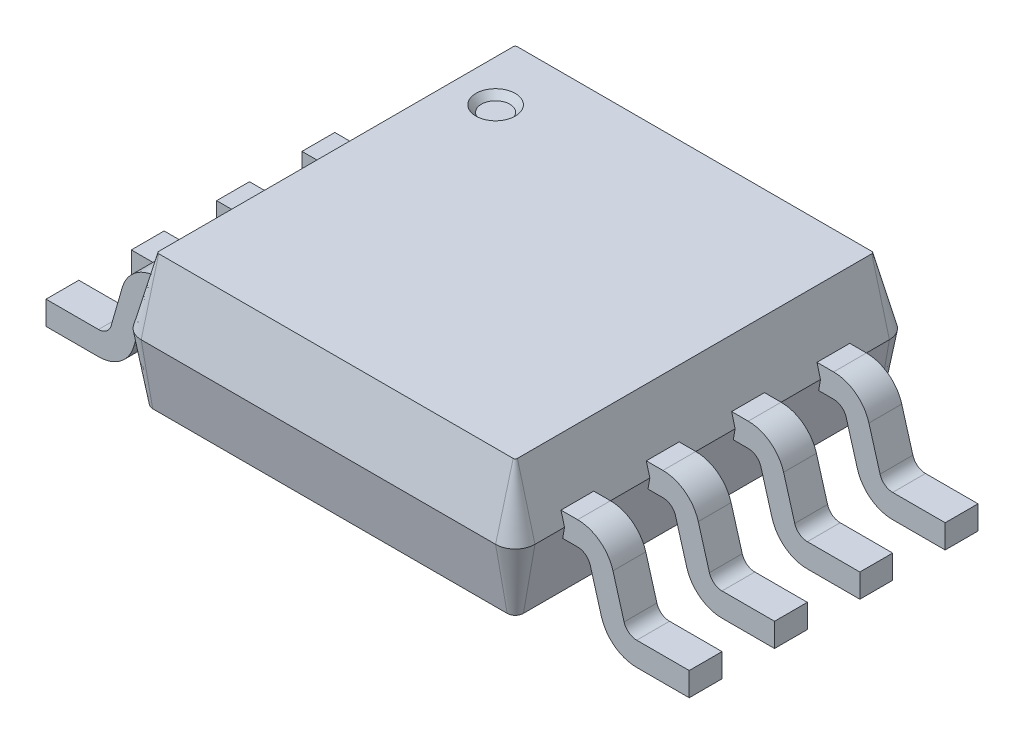
from build123d import *

# Parameters (mm, degrees)
EXTRUDE1_START           = 0.65
EXTRUDE1_DEPTH           = 0.5
EXTRUDE1_TAPER           = 15
EXTRUDE1_OTHER_WAY_DEPTH = 0.5
EXTRUDE1_OTHER_WAY_TAPER = 10
ICE1_START               = 1
ICE1_DEPTH               = 0.125
LPATTERN1_COUNT          = 4
LPATTERN1_PITCH          = 0.65
SKETCH2_R                = 0.15
ICE2_DEPTH               = 0.05
ICE2_TAPER               = 40


with BuildPart() as part:
    # Sketch1 → Extrude1 (new body)
    with BuildSketch(Plane(origin=(0, 0, 0), x_dir=(1, 0, 0), z_dir=(0, 1, 0)).offset(EXTRUDE1_START)):
        with BuildLine():
            ThreePointArc((-1.35, 1.5), (-1.456066017, 1.456066017), (-1.5, 1.35))
            Line((-1.5, 1.35), (-1.5, -1.35))
            ThreePointArc((-1.5, -1.35), (-1.456066017, -1.456066017), (-1.35, -1.5))
            Line((-1.35, -1.5), (1.35, -1.5))
            ThreePointArc((1.35, -1.5), (1.456066017, -1.456066017), (1.5, -1.35))
            Line((1.5, -1.35), (1.5, 1.35))
            ThreePointArc((1.5, 1.35), (1.456066017, 1.456066017), (1.35, 1.5))
            Line((1.35, 1.5), (-1.35, 1.5))
        make_face()
    extrude(amount=EXTRUDE1_DEPTH, taper=EXTRUDE1_TAPER)

    # Sketch1 → Extrude1 other way (add)
    with BuildSketch(Plane(origin=(0, 0, 0), x_dir=(1, 0, 0), z_dir=(0, 1, 0)).offset(EXTRUDE1_START)):
        with BuildLine():
            ThreePointArc((-1.35, 1.5), (-1.456066017, 1.456066017), (-1.5, 1.35))
            Line((-1.5, 1.35), (-1.5, -1.35))
            ThreePointArc((-1.5, -1.35), (-1.456066017, -1.456066017), (-1.35, -1.5))
            Line((-1.35, -1.5), (1.35, -1.5))
            ThreePointArc((1.35, -1.5), (1.456066017, -1.456066017), (1.5, -1.35))
            Line((1.5, -1.35), (1.5, 1.35))
            ThreePointArc((1.5, 1.35), (1.456066017, 1.456066017), (1.35, 1.5))
            Line((1.35, 1.5), (-1.35, 1.5))
        make_face()
    extrude(amount=-EXTRUDE1_OTHER_WAY_DEPTH, taper=EXTRUDE1_OTHER_WAY_TAPER)

    # Sketch3 → ICE1 (add, symmetric)
    with BuildSketch(Plane.XY.offset(ICE1_START)):
        with BuildLine():
            Line((-2.45, 0), (-2.05, 0))
            ThreePointArc((-2.05, 0), (-1.881563475, 0.05632806), (-1.780896254, 0.202649022))
            Line((-1.780896254, 0.202649022), (-1.696108481, 0.497625349))
            ThreePointArc((-1.696108481, 0.497625349), (-1.660155902, 0.549882836), (-1.6, 0.57))
            Line((-1.6, 0.57), (-1.45, 0.57))
            Line((-1.45, 0.57), (-1.45, 0.75))
            Line((-1.45, 0.75), (-1.6, 0.75))
            ThreePointArc((-1.6, 0.75), (-1.768436525, 0.69367194), (-1.869103746, 0.547350978))
            Line((-1.869103746, 0.547350978), (-1.953891519, 0.252374651))
            ThreePointArc((-1.953891519, 0.252374651), (-1.989844098, 0.200117164), (-2.05, 0.18))
            Line((-2.05, 0.18), (-2.45, 0.18))
            Line((-2.45, 0.18), (-2.45, 0))
        make_face()
        with BuildLine():
            Line((1.45, 0.75), (1.6, 0.75))
            ThreePointArc((1.6, 0.75), (1.768436525, 0.69367194), (1.869103746, 0.547350978))
            Line((1.869103746, 0.547350978), (1.953891519, 0.252374651))
            ThreePointArc((1.953891519, 0.252374651), (1.989844098, 0.200117164), (2.05, 0.18))
            Line((2.05, 0.18), (2.45, 0.18))
            Line((2.45, 0.18), (2.45, 0))
            Line((2.45, 0), (2.05, 0))
            ThreePointArc((2.05, 0), (1.881563475, 0.05632806), (1.780896254, 0.202649022))
            Line((1.780896254, 0.202649022), (1.696108481, 0.497625349))
            ThreePointArc((1.696108481, 0.497625349), (1.660155902, 0.549882836), (1.6, 0.57))
            Line((1.6, 0.57), (1.45, 0.57))
            Line((1.45, 0.57), (1.45, 0.75))
        make_face()
    ice1 = extrude(amount=ICE1_DEPTH, both=True)

    # LPattern1: ICE1 ×4
    with Locations(*[(0, 0, -i * LPATTERN1_PITCH) for i in range(1, LPATTERN1_COUNT)]):
        add(ice1)

    # Sketch2 → ICE2 (cut)
    with BuildSketch(Plane(origin=(0, 1.15, 0), x_dir=(1, 0, 0), z_dir=(0, 1, 0))):
        with Locations((-1.05, 0.9)):
            Circle(SKETCH2_R)
    extrude(amount=-ICE2_DEPTH, taper=ICE2_TAPER, mode=Mode.SUBTRACT)


solid = part.part
